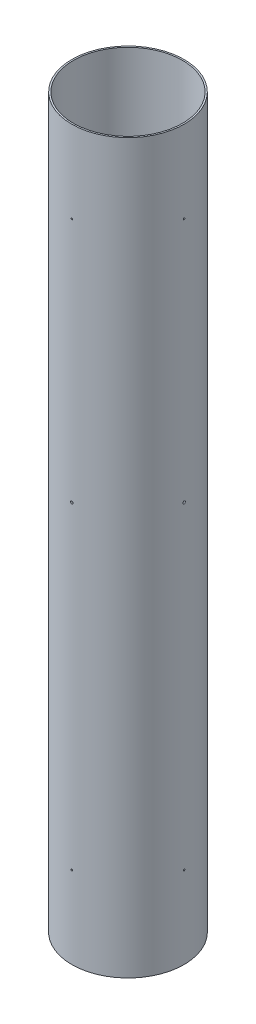
from build123d import *

# Parameters (mm, degrees)
SKETCH1_R           = 78.359
SKETCH1_R_2         = 76.1746
BOSS_EXTRUDE1_DEPTH = 1016
SKETCH3_R           = 1.750000056
SKETCH3_R_2         = 1.0922
CUT_EXTRUDE1_DEPTH  = 1023.025570014
CIRPATTERN1_COUNT   = 4


with BuildPart() as part:
    # Sketch1 → Boss-Extrude1 (new body)
    with BuildSketch(Plane(origin=(0, 0, 0), x_dir=(1, 0, 0), z_dir=(0, 1, 0))):
        with Locations(Location((0, 0, 0), (0, 0, 270))):
            Circle(SKETCH1_R)
        with Locations(Location((0, 0, 0), (0, 0, 270))):
            Circle(SKETCH1_R_2, mode=Mode.SUBTRACT)
    extrude(amount=BOSS_EXTRUDE1_DEPTH)

    # Sketch3 → Cut-Extrude1 (cut, through all)
    with BuildSketch(Plane.XY):
        with Locations(Location((0, 558.8, 0), (0, 0, 90))):
            Circle(SKETCH3_R)
        with Locations(Location((0, 114.3, 0), (0, 0, 90))):
            Circle(SKETCH3_R_2)
        with Locations(Location((0, 901.7, 0), (0, 0, 90))):
            Circle(SKETCH3_R_2)
    cut_extrude1 = extrude(amount=-CUT_EXTRUDE1_DEPTH, mode=Mode.SUBTRACT)

    # CirPattern1: Cut-Extrude1 ×4 about axis
    cirpattern1_axis = Axis((0, 1016, 0), (0, -1, 0))
    for i in range(1, CIRPATTERN1_COUNT):
        add(cut_extrude1.rotate(cirpattern1_axis, i * 360 / CIRPATTERN1_COUNT), mode=Mode.SUBTRACT)


solid = part.part
